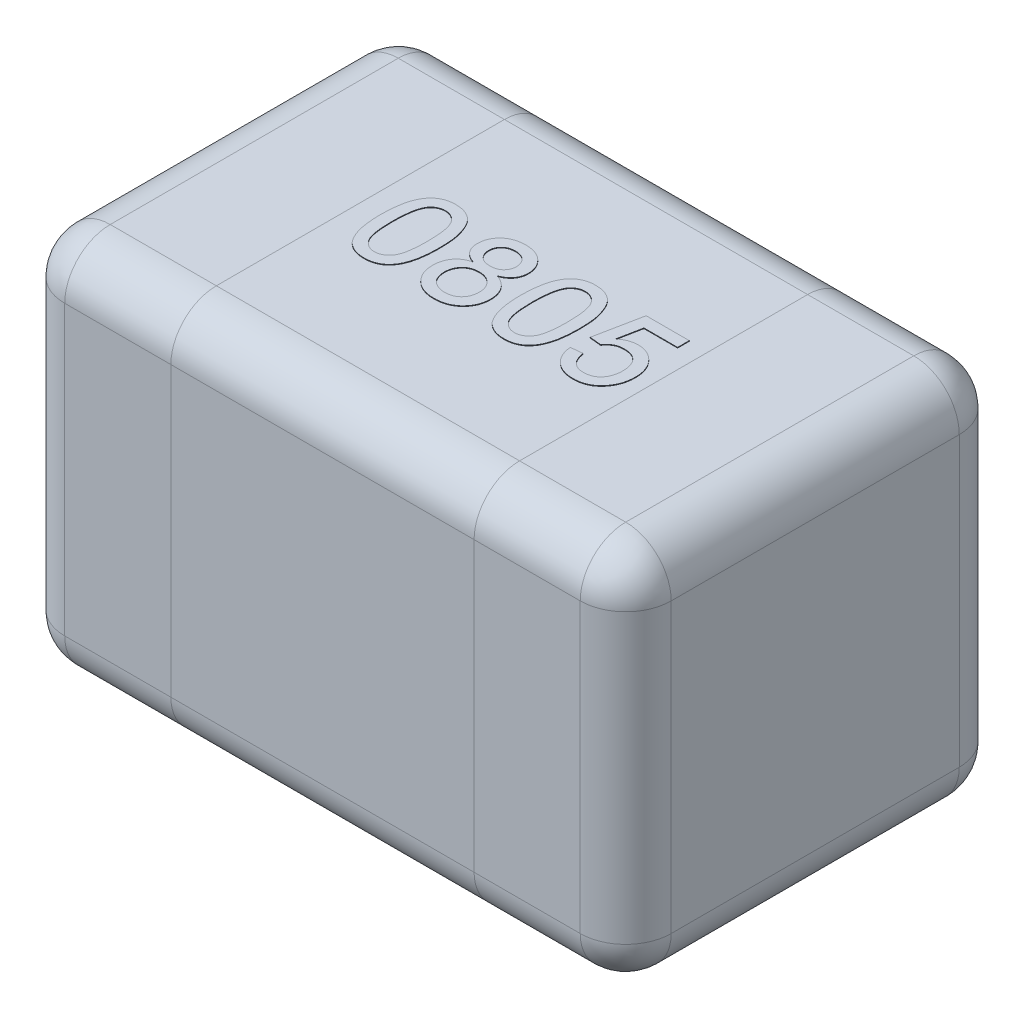
from build123d import *

# Parameters (mm, degrees)
SKETCH1_W      = 2
SKETCH1_H      = 1.25
EXTRUDE1_DEPTH = 1.25
FILLET1_R      = 0.15
EXTRUDE2_DEPTH = 0.002


with BuildPart() as part:
    # Sketch1 → Extrude1 (new body)
    with BuildSketch(Plane(origin=(0, 0, 0), x_dir=(1, 0, 0), z_dir=(0, 1, 0))):
        Rectangle(SKETCH1_W, SKETCH1_H)
    extrude(amount=EXTRUDE1_DEPTH)

    # Fillet1
    fillet1_edges = [part.edges().sort_by_distance(p)[0] for p in [
        (1, 1.25, 0),
        (0, 1.25, -0.625),
        (-1, 1.25, 0),
        (0, 0, -0.625),
        (1, 0, 0),
        (0, 0, 0.625),
        (-1, 0, 0),
        (0, 1.25, 0.625),
        (-1, 0.625, -0.625),
        (1, 0.625, -0.625),
        (1, 0.625, 0.625),
        (-1, 0.625, 0.625),
    ]]
    fillet(fillet1_edges, radius=FILLET1_R)

    # Sketch3 → Extrude2 (add)
    with BuildSketch(Plane(origin=(0, 1.25, 0), x_dir=(1, 0, 0), z_dir=(0, 1, 0))):
        with BuildLine():
            add(Edge.make_bspline(
                [(-0.430769231, -0.002043269), (-0.430730481, 0.002244006), (-0.430654586, 0.010640973), (-0.430183834, 0.022927244), (-0.42936194, 0.034595007), (-0.428135078, 0.045634129), (-0.426682243, 0.056069528), (-0.424793549, 0.06588631), (-0.422668494, 0.075106502), (-0.420118809, 0.083720493), (-0.41731754, 0.091802347), (-0.414139411, 0.0993391), (-0.410563584, 0.106322761), (-0.40676579, 0.112825754), (-0.402546105, 0.118746931), (-0.39815922, 0.124252464), (-0.393286323, 0.129140445), (-0.388130039, 0.13353664), (-0.382614442, 0.137416027), (-0.376768712, 0.140763469), (-0.370615345, 0.143719019), (-0.364037062, 0.145943957), (-0.357170429, 0.147757753), (-0.349962588, 0.149092003), (-0.342405598, 0.149878588), (-0.337241458, 0.149959072), (-0.334615385, 0.15)],
                knots=[0, 0, 0, 0, 1.2862e-05, 2.5191e-05, 3.688e-05, 4.7943e-05, 5.8507e-05, 6.8478e-05, 7.7924e-05, 8.6881e-05, 9.5415e-05, 0.000103574, 0.000111395, 0.00011894, 0.000126142, 0.000133191, 0.000140033, 0.000146812, 0.000153498, 0.000160229, 0.000167003, 0.000173941, 0.000181025, 0.000188297, 0.00019591, 0.000203786, 0.000203786, 0.000203786, 0.000203786], degree=3))
            add(Edge.make_bspline(
                [(-0.334615385, 0.15), (-0.330762593, 0.149886731), (-0.32319363, 0.149664209), (-0.312142905, 0.147849358), (-0.301728309, 0.144744777), (-0.291956608, 0.140556563), (-0.282994848, 0.135236725), (-0.274991618, 0.128769652), (-0.268033247, 0.121223246), (-0.262195674, 0.112508085), (-0.257093053, 0.102864591), (-0.252559996, 0.092249481), (-0.248462244, 0.080674651), (-0.24555439, 0.070313561), (-0.243480221, 0.061369501), (-0.242107285, 0.053992694), (-0.240967473, 0.046033077), (-0.240094223, 0.037509907), (-0.239377743, 0.028432744), (-0.238824437, 0.018795935), (-0.238543578, 0.008575397), (-0.238489398, 0.001562641), (-0.238461538, -0.002043269)],
                knots=[0, 0, 0, 0, 1.1554e-05, 2.2698e-05, 3.348e-05, 4.4085e-05, 5.4516e-05, 6.4643e-05, 7.485e-05, 8.5185e-05, 9.602e-05, 0.000107541, 0.000119781, 0.000132832, 0.000139801, 0.000147321, 0.000155335, 0.000163916, 0.000173019, 0.00018265, 0.000192871, 0.000203689, 0.000203689, 0.000203689, 0.000203689], degree=3))
            add(Edge.make_bspline(
                [(-0.238461538, -0.002043269), (-0.238501014, -0.006310407), (-0.238578138, -0.0146471), (-0.239036276, -0.026834856), (-0.239907695, -0.038414591), (-0.240979992, -0.049412832), (-0.242602154, -0.059800218), (-0.24435012, -0.069620882), (-0.246511923, -0.07883023), (-0.249034239, -0.087432298), (-0.251874941, -0.095472571), (-0.254990209, -0.103011813), (-0.258440668, -0.110044871), (-0.262329015, -0.11650315), (-0.266477343, -0.122472371), (-0.270916032, -0.127974928), (-0.275739189, -0.132931621), (-0.280941938, -0.137314631), (-0.28641881, -0.141262812), (-0.292278751, -0.144643304), (-0.298496114, -0.147443983), (-0.305029358, -0.149838424), (-0.311944772, -0.15159293), (-0.319187822, -0.152935977), (-0.326785196, -0.153726861), (-0.331969311, -0.153805841), (-0.334615385, -0.153846154)],
                knots=[0, 0, 0, 0, 1.2802e-05, 2.5011e-05, 3.658e-05, 4.7637e-05, 5.815e-05, 6.811e-05, 7.7556e-05, 8.6513e-05, 9.499e-05, 0.000103126, 0.000110974, 0.000118467, 0.000125719, 0.000132767, 0.000139652, 0.000146431, 0.000153152, 0.000159883, 0.000166686, 0.000173587, 0.000180729, 0.000188061, 0.000195673, 0.00020361, 0.00020361, 0.00020361, 0.00020361], degree=3))
            add(Edge.make_bspline(
                [(-0.334615385, -0.153846154), (-0.338084694, -0.153747192), (-0.344848894, -0.153554242), (-0.354727508, -0.152243272), (-0.363999114, -0.149935902), (-0.372741914, -0.146841394), (-0.380857634, -0.142702311), (-0.388385026, -0.137666308), (-0.395475345, -0.131850554), (-0.399556964, -0.127262057), (-0.401622596, -0.124939904)],
                knots=[0, 0, 0, 0, 1.0408e-05, 2.0292e-05, 2.9825e-05, 3.9025e-05, 4.8056e-05, 5.7073e-05, 6.616e-05, 7.5471e-05, 7.5471e-05, 7.5471e-05, 7.5471e-05], degree=3))
            add(Edge.make_bspline(
                [(-0.401622596, -0.124939904), (-0.404000186, -0.121510195), (-0.408902879, -0.11443799), (-0.414641055, -0.102379223), (-0.41975961, -0.089104214), (-0.423776737, -0.074352508), (-0.426923149, -0.058241513), (-0.429195644, -0.040739616), (-0.430481652, -0.021854376), (-0.430671207, -0.008796046), (-0.430769231, -0.002043269)],
                knots=[0, 0, 0, 0, 1.2501e-05, 2.5778e-05, 3.993e-05, 5.5152e-05, 7.157e-05, 8.9147e-05, 0.000108063, 0.000128321, 0.000128321, 0.000128321, 0.000128321], degree=3))
        make_face()
        with BuildLine():
            add(Edge.make_bspline(
                [(-0.392307692, -0.001923077), (-0.392269503, -0.007693168), (-0.3921964, -0.018738399), (-0.391432655, -0.034518417), (-0.390117899, -0.048754147), (-0.388379705, -0.061425879), (-0.386084585, -0.072550754), (-0.383202791, -0.082100422), (-0.379954324, -0.090189501), (-0.375934407, -0.096717734), (-0.371533042, -0.102039196), (-0.366988934, -0.106615825), (-0.362195175, -0.110505855), (-0.357183043, -0.113749347), (-0.351874773, -0.116205105), (-0.346328409, -0.117985045), (-0.340542745, -0.119009373), (-0.336602445, -0.119156549), (-0.334615385, -0.119230769)],
                knots=[0, 0, 0, 0, 1.7309e-05, 3.3134e-05, 4.7378e-05, 6.0186e-05, 7.1489e-05, 8.1413e-05, 9.0085e-05, 9.7558e-05, 0.000104306, 0.000110765, 0.000116876, 0.000122794, 0.000128628, 0.000134368, 0.000140227, 0.000146187, 0.000146187, 0.000146187, 0.000146187], degree=3))
            add(Edge.make_bspline(
                [(-0.334615385, -0.119230769), (-0.332628822, -0.119154928), (-0.328689509, -0.119004535), (-0.322890476, -0.118002795), (-0.317365692, -0.116131225), (-0.312065336, -0.11368414), (-0.307016775, -0.110514577), (-0.30224656, -0.106609854), (-0.297678514, -0.102035942), (-0.29329692, -0.096652628), (-0.289307629, -0.090094213), (-0.285998225, -0.082011723), (-0.283161342, -0.072445331), (-0.280853628, -0.061326124), (-0.279108264, -0.048674427), (-0.277801457, -0.03447818), (-0.2770326, -0.018718466), (-0.276960704, -0.007693194), (-0.276923077, -0.001923077)],
                knots=[0, 0, 0, 0, 5.96e-06, 1.1819e-05, 1.7578e-05, 2.3412e-05, 2.9298e-05, 3.5408e-05, 4.1867e-05, 4.8662e-05, 5.6186e-05, 6.4803e-05, 7.4784e-05, 8.6088e-05, 9.8836e-05, 0.00011308, 0.000128845, 0.000146154, 0.000146154, 0.000146154, 0.000146154], degree=3))
            add(Edge.make_bspline(
                [(-0.276923077, -0.001923077), (-0.276959499, 0.003726983), (-0.277029283, 0.014552283), (-0.27781797, 0.030028299), (-0.279053912, 0.044025088), (-0.280744486, 0.056555555), (-0.282991257, 0.067606095), (-0.285716284, 0.077200235), (-0.288963562, 0.085317512), (-0.292824563, 0.092039466), (-0.29712263, 0.097553292), (-0.301612368, 0.102325988), (-0.306406022, 0.10638501), (-0.31158852, 0.109641218), (-0.316992821, 0.112268205), (-0.322743102, 0.114076165), (-0.328782842, 0.115186918), (-0.332927837, 0.115317963), (-0.335036058, 0.115384615)],
                knots=[0, 0, 0, 0, 1.6949e-05, 3.2473e-05, 4.6473e-05, 5.9094e-05, 7.0385e-05, 8.0274e-05, 8.8979e-05, 9.6545e-05, 0.000103444, 0.000109906, 0.000116177, 0.000122229, 0.000128223, 0.000134153, 0.000140259, 0.000146579, 0.000146579, 0.000146579, 0.000146579], degree=3))
            add(Edge.make_bspline(
                [(-0.335036058, 0.115384615), (-0.337022993, 0.115332466), (-0.340940974, 0.115229635), (-0.346677413, 0.114248109), (-0.352113768, 0.112606778), (-0.357312323, 0.110383437), (-0.362143298, 0.107391258), (-0.366798279, 0.103897677), (-0.371059245, 0.099641138), (-0.373626865, 0.096459016), (-0.374939904, 0.094831731)],
                knots=[0, 0, 0, 0, 5.957e-06, 1.1747e-05, 1.7393e-05, 2.2965e-05, 2.8654e-05, 3.4399e-05, 4.0391e-05, 4.6662e-05, 4.6662e-05, 4.6662e-05, 4.6662e-05], degree=3))
            add(Edge.make_bspline(
                [(-0.374939904, 0.094831731), (-0.376369403, 0.092441753), (-0.379388204, 0.087394622), (-0.382766067, 0.078622501), (-0.385749937, 0.068597636), (-0.388206652, 0.057165788), (-0.389983913, 0.044346567), (-0.391386991, 0.03015486), (-0.392115838, 0.014570853), (-0.392241977, 0.003726591), (-0.392307692, -0.001923077)],
                knots=[0, 0, 0, 0, 8.341e-06, 1.7615e-05, 2.8091e-05, 3.9714e-05, 5.2649e-05, 6.6899e-05, 8.2483e-05, 9.9433e-05, 9.9433e-05, 9.9433e-05, 9.9433e-05], degree=3))
        make_face(mode=Mode.SUBTRACT)
        with BuildLine():
            add(Edge.make_bspline(
                [(-0.143028846, 0.014543269), (-0.146678167, 0.015970904), (-0.153675125, 0.018708154), (-0.163112218, 0.024186161), (-0.171099208, 0.030487887), (-0.177538027, 0.037765293), (-0.182445577, 0.045867936), (-0.185979208, 0.054692508), (-0.188048917, 0.06428817), (-0.188321315, 0.070923324), (-0.188461538, 0.074338942)],
                knots=[0, 0, 0, 0, 1.1742e-05, 2.2513e-05, 3.2603e-05, 4.214e-05, 5.1498e-05, 6.0884e-05, 7.0537e-05, 8.0779e-05, 8.0779e-05, 8.0779e-05, 8.0779e-05], degree=3))
            add(Edge.make_bspline(
                [(-0.188461538, 0.074338942), (-0.188395542, 0.07696711), (-0.188265988, 0.082126286), (-0.187146613, 0.089696504), (-0.185353774, 0.096950666), (-0.182809315, 0.103868299), (-0.179621525, 0.11050634), (-0.175599072, 0.11674318), (-0.170975512, 0.122755082), (-0.165559231, 0.128299027), (-0.159590583, 0.133376745), (-0.153125606, 0.137895415), (-0.146114829, 0.141590589), (-0.138675143, 0.144680065), (-0.130769761, 0.147098798), (-0.122370837, 0.148746091), (-0.113507979, 0.149793891), (-0.107434938, 0.149930227), (-0.104326923, 0.15)],
                knots=[0, 0, 0, 0, 7.881e-06, 1.547e-05, 2.2904e-05, 3.0261e-05, 3.7545e-05, 4.4948e-05, 5.2485e-05, 6.0262e-05, 6.8149e-05, 7.5968e-05, 8.3872e-05, 9.1874e-05, 0.000100106, 0.000108627, 0.00011752, 0.000126842, 0.000126842, 0.000126842, 0.000126842], degree=3))
            add(Edge.make_bspline(
                [(-0.104326923, 0.15), (-0.101199104, 0.149929518), (-0.095106464, 0.149792228), (-0.086196519, 0.148758507), (-0.077744593, 0.147025925), (-0.06975566, 0.144567827), (-0.062217127, 0.141425001), (-0.05517853, 0.137562056), (-0.048567409, 0.133042703), (-0.042552743, 0.127813048), (-0.037080114, 0.122135343), (-0.032338597, 0.1160526), (-0.02827195, 0.109706754), (-0.024911477, 0.103059254), (-0.022425386, 0.096034402), (-0.020530427, 0.088764549), (-0.019431263, 0.081163316), (-0.019298434, 0.076005089), (-0.019230769, 0.073377404)],
                knots=[0, 0, 0, 0, 9.382e-06, 1.8275e-05, 2.6867e-05, 3.5231e-05, 4.3312e-05, 5.1326e-05, 5.9277e-05, 6.7288e-05, 7.5194e-05, 8.29e-05, 9.0385e-05, 9.7776e-05, 0.00010519, 0.000112697, 0.000120286, 0.000128167, 0.000128167, 0.000128167, 0.000128167], degree=3))
            add(Edge.make_bspline(
                [(-0.019230769, 0.073377404), (-0.019340689, 0.070079507), (-0.019556221, 0.063612951), (-0.021752586, 0.054291357), (-0.025175809, 0.045589182), (-0.030123399, 0.037672273), (-0.036389338, 0.030458869), (-0.044164868, 0.024188177), (-0.053331905, 0.018718731), (-0.060152201, 0.015972556), (-0.063701923, 0.014543269)],
                knots=[0, 0, 0, 0, 9.878e-06, 1.9369e-05, 2.8564e-05, 3.782e-05, 4.7233e-05, 5.7098e-05, 6.7662e-05, 7.9128e-05, 7.9128e-05, 7.9128e-05, 7.9128e-05], degree=3))
            add(Edge.make_bspline(
                [(-0.063701923, 0.014543269), (-0.061462279, 0.013783016), (-0.057073548, 0.01229325), (-0.050869192, 0.009396685), (-0.045027977, 0.006273501), (-0.039516964, 0.002892652), (-0.034539578, -0.000997287), (-0.02992976, -0.00516632), (-0.02570689, -0.009673198), (-0.021928648, -0.014556251), (-0.018555448, -0.019712993), (-0.015667721, -0.025155995), (-0.01321523, -0.030807785), (-0.011119246, -0.036694571), (-0.009588296, -0.042857817), (-0.008517111, -0.049269202), (-0.007837474, -0.055894934), (-0.0077412, -0.060394987), (-0.007692308, -0.062680288)],
                knots=[0, 0, 0, 0, 7.091e-06, 1.3894e-05, 2.0509e-05, 2.6962e-05, 3.326e-05, 3.9429e-05, 4.5594e-05, 5.1761e-05, 5.7929e-05, 6.4058e-05, 7.0221e-05, 7.6399e-05, 8.2783e-05, 8.9244e-05, 9.5888e-05, 0.000102743, 0.000102743, 0.000102743, 0.000102743], degree=3))
            add(Edge.make_bspline(
                [(-0.007692308, -0.062680288), (-0.007768742, -0.065830053), (-0.007919323, -0.07203533), (-0.009242375, -0.081143948), (-0.011244211, -0.089894018), (-0.014163119, -0.098248578), (-0.017891291, -0.106213532), (-0.022503083, -0.113777315), (-0.027953185, -0.120932146), (-0.034080828, -0.127700265), (-0.040931529, -0.133818351), (-0.048342718, -0.139209736), (-0.056342204, -0.143725707), (-0.064832924, -0.147464915), (-0.073855537, -0.150362788), (-0.083398443, -0.152391913), (-0.093458467, -0.153600168), (-0.100337199, -0.15376306), (-0.103846154, -0.153846154)],
                knots=[0, 0, 0, 0, 9.444e-06, 1.8606e-05, 2.7557e-05, 3.6337e-05, 4.5101e-05, 5.3893e-05, 6.2859e-05, 7.2048e-05, 8.1241e-05, 9.0365e-05, 9.9489e-05, 0.000108745, 0.000118153, 0.000127865, 0.000137973, 0.000148498, 0.000148498, 0.000148498, 0.000148498], degree=3))
            add(Edge.make_bspline(
                [(-0.103846154, -0.153846154), (-0.107354757, -0.153761269), (-0.114232802, -0.153594866), (-0.124302017, -0.152411313), (-0.13383127, -0.150290202), (-0.142842151, -0.147389384), (-0.15138354, -0.143751415), (-0.159329302, -0.139133687), (-0.166788901, -0.133749133), (-0.173644365, -0.127593205), (-0.179822907, -0.120825808), (-0.185201165, -0.113565311), (-0.18978558, -0.105923451), (-0.193558454, -0.097857148), (-0.196434244, -0.089366329), (-0.198452508, -0.080482873), (-0.199777955, -0.071213566), (-0.199924942, -0.064888503), (-0.2, -0.061658654)],
                knots=[0, 0, 0, 0, 1.0525e-05, 2.0633e-05, 3.0358e-05, 3.9766e-05, 4.8998e-05, 5.8152e-05, 6.7276e-05, 7.6554e-05, 8.5742e-05, 9.4721e-05, 0.000103615, 0.000112434, 0.000121385, 0.000130452, 0.000139733, 0.000149418, 0.000149418, 0.000149418, 0.000149418], degree=3))
            add(Edge.make_bspline(
                [(-0.2, -0.061658654), (-0.199947829, -0.05925379), (-0.199845461, -0.054535032), (-0.199220126, -0.047613898), (-0.197973847, -0.04101733), (-0.19636856, -0.034706454), (-0.194330348, -0.028665483), (-0.191815826, -0.022941855), (-0.188765062, -0.017549405), (-0.185299194, -0.012453043), (-0.181374488, -0.007688549), (-0.177054552, -0.003297645), (-0.172323696, 0.000669723), (-0.16728823, 0.004329433), (-0.161737085, 0.007422605), (-0.155876706, 0.010261167), (-0.149606339, 0.012681934), (-0.145243302, 0.01391661), (-0.143028846, 0.014543269)],
                knots=[0, 0, 0, 0, 7.216e-06, 1.4158e-05, 2.0818e-05, 2.7333e-05, 3.3681e-05, 3.9923e-05, 4.6058e-05, 5.2242e-05, 5.839e-05, 6.4552e-05, 7.0692e-05, 7.6896e-05, 8.3194e-05, 8.9726e-05, 9.6422e-05, 0.000103324, 0.000103324, 0.000103324, 0.000103324], degree=3))
        make_face()
        with BuildLine():
            add(Edge.make_bspline(
                [(-0.15, 0.074158654), (-0.149885847, 0.071096846), (-0.149665252, 0.065180074), (-0.147266257, 0.056775734), (-0.143514926, 0.049226279), (-0.139117148, 0.043751589), (-0.134900784, 0.0400214), (-0.131381647, 0.037530885), (-0.127535911, 0.035416488), (-0.123335716, 0.033773046), (-0.11888279, 0.032317058), (-0.114023557, 0.031503267), (-0.108872232, 0.030841703), (-0.105311001, 0.03079379), (-0.103485577, 0.030769231)],
                knots=[0, 0, 0, 0, 9.163e-06, 1.7707e-05, 2.5985e-05, 3.4319e-05, 3.8576e-05, 4.2845e-05, 4.7228e-05, 5.1704e-05, 5.6361e-05, 6.1252e-05, 6.6455e-05, 7.1927e-05, 7.1927e-05, 7.1927e-05, 7.1927e-05], degree=3))
            add(Edge.make_bspline(
                [(-0.103485577, 0.030769231), (-0.101700447, 0.030794697), (-0.098219542, 0.030844356), (-0.093184237, 0.031492433), (-0.088425891, 0.032358), (-0.08401482, 0.033669634), (-0.079900096, 0.035375141), (-0.076148645, 0.037477611), (-0.072648204, 0.039893951), (-0.068555701, 0.043652639), (-0.064163992, 0.048935583), (-0.060400089, 0.056147793), (-0.058054585, 0.064038379), (-0.057815187, 0.069534632), (-0.057692308, 0.072355769)],
                knots=[0, 0, 0, 0, 5.352e-06, 1.0435e-05, 1.5209e-05, 1.9848e-05, 2.4212e-05, 2.8543e-05, 3.2728e-05, 3.694e-05, 4.5181e-05, 5.3192e-05, 6.1199e-05, 6.9644e-05, 6.9644e-05, 6.9644e-05, 6.9644e-05], degree=3))
            add(Edge.make_bspline(
                [(-0.057692308, 0.072355769), (-0.05784036, 0.075275526), (-0.05813006, 0.080988733), (-0.060469834, 0.089190299), (-0.06440905, 0.096618469), (-0.068909058, 0.102043156), (-0.073073957, 0.105973023), (-0.076637241, 0.108474646), (-0.080467784, 0.110603749), (-0.084580166, 0.112342448), (-0.088980333, 0.113744726), (-0.093680205, 0.114664689), (-0.098660033, 0.115309891), (-0.102081073, 0.115359183), (-0.103846154, 0.115384615)],
                knots=[0, 0, 0, 0, 8.749e-06, 1.7119e-05, 2.5345e-05, 3.3802e-05, 3.814e-05, 4.2492e-05, 4.6823e-05, 5.1266e-05, 5.5866e-05, 6.0651e-05, 6.5615e-05, 7.0907e-05, 7.0907e-05, 7.0907e-05, 7.0907e-05], degree=3))
            add(Edge.make_bspline(
                [(-0.103846154, 0.115384615), (-0.105611431, 0.115360006), (-0.109052754, 0.11531203), (-0.114065054, 0.114647467), (-0.118809467, 0.113812789), (-0.123242222, 0.112473285), (-0.127344894, 0.110722865), (-0.131160335, 0.108592567), (-0.134716868, 0.106154844), (-0.138911028, 0.102400216), (-0.14330372, 0.097117152), (-0.147173559, 0.09002013), (-0.149565244, 0.08228198), (-0.149853286, 0.076899968), (-0.15, 0.074158654)],
                knots=[0, 0, 0, 0, 5.292e-06, 1.0316e-05, 1.5148e-05, 1.973e-05, 2.4173e-05, 2.8504e-05, 3.2821e-05, 3.7078e-05, 4.5358e-05, 5.3291e-05, 6.12e-05, 6.941e-05, 6.941e-05, 6.941e-05, 6.941e-05], degree=3))
        make_face(mode=Mode.SUBTRACT)
        with BuildLine():
            add(Edge.make_bspline(
                [(-0.161538462, -0.0609375), (-0.161471953, -0.063405403), (-0.16133876, -0.06834771), (-0.160170375, -0.075688083), (-0.158187867, -0.082891764), (-0.155646938, -0.089965559), (-0.1520628, -0.096623957), (-0.147309829, -0.102567066), (-0.141345741, -0.107563675), (-0.134534427, -0.111784999), (-0.127101532, -0.115107544), (-0.119356237, -0.117426794), (-0.111498446, -0.118959238), (-0.106196901, -0.119140248), (-0.103545673, -0.119230769)],
                knots=[0, 0, 0, 0, 7.401e-06, 1.4821e-05, 2.2226e-05, 2.9795e-05, 3.7325e-05, 4.4805e-05, 5.2477e-05, 6.0548e-05, 6.8779e-05, 7.6821e-05, 8.4765e-05, 9.2713e-05, 9.2713e-05, 9.2713e-05, 9.2713e-05], degree=3))
            add(Edge.make_bspline(
                [(-0.103545673, -0.119230769), (-0.10135945, -0.119193736), (-0.097112242, -0.119121792), (-0.090921142, -0.11829967), (-0.085087726, -0.117052243), (-0.079585269, -0.115341816), (-0.074494761, -0.113001839), (-0.069733304, -0.110266914), (-0.065349603, -0.106961547), (-0.061344897, -0.10318929), (-0.057759976, -0.099016466), (-0.054689038, -0.094514901), (-0.052010223, -0.08981119), (-0.049823092, -0.08480382), (-0.048241444, -0.079482465), (-0.04702098, -0.073943134), (-0.046284709, -0.068128692), (-0.046198099, -0.064164781), (-0.046153846, -0.062139423)],
                knots=[0, 0, 0, 0, 6.555e-06, 1.2734e-05, 1.8699e-05, 2.4438e-05, 2.9979e-05, 3.5473e-05, 4.0881e-05, 4.6408e-05, 5.1949e-05, 5.735e-05, 6.2732e-05, 6.8169e-05, 7.37e-05, 7.9358e-05, 8.5173e-05, 9.1247e-05, 9.1247e-05, 9.1247e-05, 9.1247e-05], degree=3))
            add(Edge.make_bspline(
                [(-0.046153846, -0.062139423), (-0.046199509, -0.06007431), (-0.046288909, -0.056031148), (-0.047006468, -0.050089091), (-0.048295369, -0.044452304), (-0.0499529, -0.039035631), (-0.052199329, -0.033933308), (-0.054895853, -0.029072172), (-0.058197999, -0.024580352), (-0.061819065, -0.020305352), (-0.0659169, -0.016435488), (-0.070442192, -0.013098358), (-0.075251524, -0.010151107), (-0.080490384, -0.007890317), (-0.086043352, -0.006079372), (-0.09193681, -0.004763512), (-0.098194786, -0.003959162), (-0.102481472, -0.003884551), (-0.1046875, -0.003846154)],
                knots=[0, 0, 0, 0, 6.195e-06, 1.2128e-05, 1.7916e-05, 2.3523e-05, 2.9094e-05, 3.4611e-05, 4.0164e-05, 4.579e-05, 5.1402e-05, 5.7027e-05, 6.2633e-05, 6.8284e-05, 7.4099e-05, 8.0135e-05, 8.6374e-05, 9.2989e-05, 9.2989e-05, 9.2989e-05, 9.2989e-05], degree=3))
            add(Edge.make_bspline(
                [(-0.1046875, -0.003846154), (-0.106833622, -0.003884933), (-0.11104069, -0.003960952), (-0.117152397, -0.004769858), (-0.122938306, -0.00601207), (-0.128347512, -0.007830212), (-0.133447646, -0.010102166), (-0.13814543, -0.012958985), (-0.142524672, -0.016274938), (-0.1464516, -0.020129101), (-0.149994708, -0.02431577), (-0.153058103, -0.028803867), (-0.155764303, -0.033489281), (-0.157817981, -0.038525757), (-0.159556235, -0.043750476), (-0.160642919, -0.049264843), (-0.161415415, -0.055006205), (-0.161496847, -0.058931505), (-0.161538462, -0.0609375)],
                knots=[0, 0, 0, 0, 6.435e-06, 1.2614e-05, 1.8461e-05, 2.4162e-05, 2.9703e-05, 3.5176e-05, 4.0621e-05, 4.6146e-05, 5.1647e-05, 5.7048e-05, 6.243e-05, 6.7843e-05, 7.3336e-05, 7.8923e-05, 8.4677e-05, 9.0691e-05, 9.0691e-05, 9.0691e-05, 9.0691e-05], degree=3))
        make_face(mode=Mode.SUBTRACT)
        with BuildLine():
            add(Edge.make_bspline(
                [(0.030769231, -0.002043269), (0.030807981, 0.002244006), (0.030883876, 0.010640973), (0.031354627, 0.022927244), (0.032176522, 0.034595007), (0.033403384, 0.045634129), (0.034856218, 0.056069528), (0.036744912, 0.06588631), (0.038869967, 0.075106502), (0.041419652, 0.083720493), (0.044220921, 0.091802347), (0.047399051, 0.0993391), (0.050974877, 0.106322761), (0.054772671, 0.112825754), (0.058992356, 0.118746931), (0.063379241, 0.124252464), (0.068252138, 0.129140445), (0.073408422, 0.13353664), (0.07892402, 0.137416027), (0.084769749, 0.140763469), (0.090923117, 0.143719019), (0.097501399, 0.145943957), (0.104368033, 0.147757753), (0.111575873, 0.149092003), (0.119132863, 0.149878588), (0.124297003, 0.149959072), (0.126923077, 0.15)],
                knots=[0, 0, 0, 0, 1.2862e-05, 2.5191e-05, 3.688e-05, 4.7943e-05, 5.8507e-05, 6.8478e-05, 7.7924e-05, 8.6881e-05, 9.5415e-05, 0.000103574, 0.000111395, 0.00011894, 0.000126142, 0.000133191, 0.000140033, 0.000146812, 0.000153498, 0.000160229, 0.000167003, 0.000173941, 0.000181025, 0.000188297, 0.00019591, 0.000203786, 0.000203786, 0.000203786, 0.000203786], degree=3))
            add(Edge.make_bspline(
                [(0.126923077, 0.15), (0.130775868, 0.149886731), (0.138344831, 0.149664209), (0.149395556, 0.147849358), (0.159810153, 0.144744777), (0.169581854, 0.140556563), (0.178543614, 0.135236725), (0.186546843, 0.128769652), (0.193505214, 0.121223246), (0.199342787, 0.112508085), (0.204445409, 0.102864591), (0.208978466, 0.092249481), (0.213076217, 0.080674651), (0.215984071, 0.070313561), (0.218058241, 0.061369501), (0.219431176, 0.053992694), (0.220570988, 0.046033077), (0.221444238, 0.037509907), (0.222160719, 0.028432744), (0.222714024, 0.018795935), (0.222994883, 0.008575397), (0.223049064, 0.001562641), (0.223076923, -0.002043269)],
                knots=[0, 0, 0, 0, 1.1554e-05, 2.2698e-05, 3.348e-05, 4.4085e-05, 5.4516e-05, 6.4643e-05, 7.485e-05, 8.5185e-05, 9.602e-05, 0.000107541, 0.000119781, 0.000132832, 0.000139801, 0.000147321, 0.000155335, 0.000163916, 0.000173019, 0.00018265, 0.000192871, 0.000203689, 0.000203689, 0.000203689, 0.000203689], degree=3))
            add(Edge.make_bspline(
                [(0.223076923, -0.002043269), (0.223037447, -0.006310407), (0.222960323, -0.0146471), (0.222502186, -0.026834856), (0.221630766, -0.038414591), (0.220558469, -0.049412832), (0.218936308, -0.059800218), (0.217188341, -0.069620882), (0.215026538, -0.07883023), (0.212504222, -0.087432298), (0.209663521, -0.095472571), (0.206548253, -0.103011813), (0.203097794, -0.110044871), (0.199209446, -0.11650315), (0.195061119, -0.122472371), (0.190622429, -0.127974928), (0.185799273, -0.132931621), (0.180596523, -0.137314631), (0.175119652, -0.141262812), (0.16925971, -0.144643304), (0.163042348, -0.147443983), (0.156509104, -0.149838424), (0.149593689, -0.15159293), (0.142350639, -0.152935977), (0.134753266, -0.153726861), (0.129569151, -0.153805841), (0.126923077, -0.153846154)],
                knots=[0, 0, 0, 0, 1.2802e-05, 2.5011e-05, 3.658e-05, 4.7637e-05, 5.815e-05, 6.811e-05, 7.7556e-05, 8.6513e-05, 9.499e-05, 0.000103126, 0.000110974, 0.000118467, 0.000125719, 0.000132767, 0.000139652, 0.000146431, 0.000153152, 0.000159883, 0.000166686, 0.000173587, 0.000180729, 0.000188061, 0.000195673, 0.00020361, 0.00020361, 0.00020361, 0.00020361], degree=3))
            add(Edge.make_bspline(
                [(0.126923077, -0.153846154), (0.123453767, -0.153747192), (0.116689568, -0.153554242), (0.106810954, -0.152243272), (0.097539347, -0.149935902), (0.088796548, -0.146841394), (0.080680827, -0.142702311), (0.073153436, -0.137666308), (0.066063116, -0.131850554), (0.061981497, -0.127262057), (0.059915865, -0.124939904)],
                knots=[0, 0, 0, 0, 1.0408e-05, 2.0292e-05, 2.9825e-05, 3.9025e-05, 4.8056e-05, 5.7073e-05, 6.616e-05, 7.5471e-05, 7.5471e-05, 7.5471e-05, 7.5471e-05], degree=3))
            add(Edge.make_bspline(
                [(0.059915865, -0.124939904), (0.057538275, -0.121510195), (0.052635583, -0.11443799), (0.046897407, -0.102379223), (0.041778852, -0.089104214), (0.037761725, -0.074352508), (0.034615313, -0.058241513), (0.032342818, -0.040739616), (0.031056809, -0.021854376), (0.030867254, -0.008796046), (0.030769231, -0.002043269)],
                knots=[0, 0, 0, 0, 1.2501e-05, 2.5778e-05, 3.993e-05, 5.5152e-05, 7.157e-05, 8.9147e-05, 0.000108063, 0.000128321, 0.000128321, 0.000128321, 0.000128321], degree=3))
        make_face()
        with BuildLine():
            add(Edge.make_bspline(
                [(0.069230769, -0.001923077), (0.069268958, -0.007693168), (0.069342061, -0.018738399), (0.070105807, -0.034518417), (0.071420563, -0.048754147), (0.073158757, -0.061425879), (0.075453876, -0.072550754), (0.07833567, -0.082100422), (0.081584138, -0.090189501), (0.085604055, -0.096717734), (0.090005419, -0.102039196), (0.094549528, -0.106615825), (0.099343287, -0.110505855), (0.104355418, -0.113749347), (0.109663688, -0.116205105), (0.115210052, -0.117985045), (0.120995717, -0.119009373), (0.124936017, -0.119156549), (0.126923077, -0.119230769)],
                knots=[0, 0, 0, 0, 1.7309e-05, 3.3134e-05, 4.7378e-05, 6.0186e-05, 7.1489e-05, 8.1413e-05, 9.0085e-05, 9.7558e-05, 0.000104306, 0.000110765, 0.000116876, 0.000122794, 0.000128628, 0.000134368, 0.000140227, 0.000146187, 0.000146187, 0.000146187, 0.000146187], degree=3))
            add(Edge.make_bspline(
                [(0.126923077, -0.119230769), (0.128909639, -0.119154928), (0.132848953, -0.119004535), (0.138647986, -0.118002795), (0.14417277, -0.116131225), (0.149473125, -0.11368414), (0.154521686, -0.110514577), (0.159291902, -0.106609854), (0.163859948, -0.102035942), (0.168241542, -0.096652628), (0.172230832, -0.090094213), (0.175540237, -0.082011723), (0.17837712, -0.072445331), (0.180684833, -0.061326124), (0.182430197, -0.048674427), (0.183737005, -0.03447818), (0.184505861, -0.018718466), (0.184577757, -0.007693194), (0.184615385, -0.001923077)],
                knots=[0, 0, 0, 0, 5.96e-06, 1.1819e-05, 1.7578e-05, 2.3412e-05, 2.9298e-05, 3.5408e-05, 4.1867e-05, 4.8662e-05, 5.6186e-05, 6.4803e-05, 7.4784e-05, 8.6088e-05, 9.8836e-05, 0.00011308, 0.000128845, 0.000146154, 0.000146154, 0.000146154, 0.000146154], degree=3))
            add(Edge.make_bspline(
                [(0.184615385, -0.001923077), (0.184578962, 0.003726983), (0.184509178, 0.014552283), (0.183720492, 0.030028299), (0.182484549, 0.044025088), (0.180793976, 0.056555555), (0.178547205, 0.067606095), (0.175822177, 0.077200235), (0.1725749, 0.085317512), (0.168713899, 0.092039466), (0.164415832, 0.097553292), (0.159926094, 0.102325988), (0.15513244, 0.10638501), (0.149949942, 0.109641218), (0.144545641, 0.112268205), (0.13879536, 0.114076165), (0.13275562, 0.115186918), (0.128610625, 0.115317963), (0.126502404, 0.115384615)],
                knots=[0, 0, 0, 0, 1.6949e-05, 3.2473e-05, 4.6473e-05, 5.9094e-05, 7.0385e-05, 8.0274e-05, 8.8979e-05, 9.6545e-05, 0.000103444, 0.000109906, 0.000116177, 0.000122229, 0.000128223, 0.000134153, 0.000140259, 0.000146579, 0.000146579, 0.000146579, 0.000146579], degree=3))
            add(Edge.make_bspline(
                [(0.126502404, 0.115384615), (0.124515469, 0.115332466), (0.120597487, 0.115229635), (0.114861049, 0.114248109), (0.109424694, 0.112606778), (0.104226139, 0.110383437), (0.099395163, 0.107391258), (0.094740182, 0.103897677), (0.090479217, 0.099641138), (0.087911597, 0.096459016), (0.086598558, 0.094831731)],
                knots=[0, 0, 0, 0, 5.957e-06, 1.1747e-05, 1.7393e-05, 2.2965e-05, 2.8654e-05, 3.4399e-05, 4.0391e-05, 4.6662e-05, 4.6662e-05, 4.6662e-05, 4.6662e-05], degree=3))
            add(Edge.make_bspline(
                [(0.086598558, 0.094831731), (0.085169059, 0.092441753), (0.082150258, 0.087394622), (0.078772395, 0.078622501), (0.075788524, 0.068597636), (0.07333181, 0.057165788), (0.071554549, 0.044346567), (0.07015147, 0.03015486), (0.069422623, 0.014570853), (0.069296485, 0.003726591), (0.069230769, -0.001923077)],
                knots=[0, 0, 0, 0, 8.341e-06, 1.7615e-05, 2.8091e-05, 3.9714e-05, 5.2649e-05, 6.6899e-05, 8.2483e-05, 9.9433e-05, 9.9433e-05, 9.9433e-05, 9.9433e-05], degree=3))
        make_face(mode=Mode.SUBTRACT)
        with BuildLine():
            Line((0.261538462, -0.069230769), (0.3, -0.065384615))
            add(Edge.make_bspline(
                [(0.3, -0.065384615), (0.30038083, -0.067551712), (0.301121602, -0.071767052), (0.302533227, -0.077868882), (0.304366525, -0.083537652), (0.306426438, -0.088822457), (0.308874991, -0.093667418), (0.31152802, -0.098149034), (0.314656724, -0.102108221), (0.317946137, -0.105752048), (0.321556518, -0.108962904), (0.325522707, -0.111669767), (0.329734042, -0.114031341), (0.334241818, -0.115964892), (0.339052942, -0.11738015), (0.344106181, -0.118499376), (0.349466606, -0.119063349), (0.353123988, -0.119174249), (0.354987981, -0.119230769)],
                knots=[0, 0, 0, 0, 6.601e-06, 1.2839e-05, 1.8769e-05, 2.4461e-05, 2.9836e-05, 3.5041e-05, 4.0053e-05, 4.4945e-05, 4.9756e-05, 5.4507e-05, 5.9322e-05, 6.4223e-05, 6.9184e-05, 7.4347e-05, 7.9729e-05, 8.5323e-05, 8.5323e-05, 8.5323e-05, 8.5323e-05], degree=3))
            add(Edge.make_bspline(
                [(0.354987981, -0.119230769), (0.357274683, -0.119175516), (0.361746428, -0.119067466), (0.368251971, -0.118153619), (0.374396983, -0.116646792), (0.380152061, -0.1145381), (0.385584673, -0.111915691), (0.390514594, -0.10852015), (0.395210632, -0.104703226), (0.399370595, -0.10015272), (0.403157331, -0.095198734), (0.406425568, -0.089791248), (0.409176962, -0.08400616), (0.411493335, -0.077844578), (0.413203807, -0.071271305), (0.414461998, -0.064321309), (0.415269706, -0.056990161), (0.415345769, -0.051965295), (0.415384615, -0.049399038)],
                knots=[0, 0, 0, 0, 6.858e-06, 1.341e-05, 1.9663e-05, 2.5804e-05, 3.177e-05, 3.7704e-05, 4.3721e-05, 4.9886e-05, 5.6149e-05, 6.2405e-05, 6.8802e-05, 7.5343e-05, 8.2122e-05, 8.9147e-05, 9.652e-05, 0.000104216, 0.000104216, 0.000104216, 0.000104216], degree=3))
            add(Edge.make_bspline(
                [(0.415384615, -0.049399038), (0.415340463, -0.04695343), (0.415254489, -0.042191262), (0.414530446, -0.035256754), (0.4133089, -0.028736217), (0.411728333, -0.022557785), (0.409549721, -0.016818003), (0.406965765, -0.01143365), (0.403800311, -0.006518997), (0.400278533, -0.001921019), (0.396256219, 0.002200882), (0.391679027, 0.005681305), (0.386726518, 0.008727379), (0.381298942, 0.011197555), (0.375393105, 0.013032802), (0.369067694, 0.01444486), (0.362257073, 0.015187545), (0.357573654, 0.015317745), (0.355168269, 0.015384615)],
                knots=[0, 0, 0, 0, 7.336e-06, 1.4284e-05, 2.0885e-05, 2.7226e-05, 3.3387e-05, 3.9274e-05, 4.5109e-05, 5.0891e-05, 5.6628e-05, 6.2325e-05, 6.8097e-05, 7.4041e-05, 8.016e-05, 8.662e-05, 9.3456e-05, 0.000100674, 0.000100674, 0.000100674, 0.000100674], degree=3))
            add(Edge.make_bspline(
                [(0.355168269, 0.015384615), (0.35217729, 0.015297123), (0.346441268, 0.015129334), (0.338199195, 0.013717778), (0.330696137, 0.011437589), (0.324017044, 0.008039245), (0.318049605, 0.003979366), (0.312669849, -0.000614572), (0.307833414, -0.005739463), (0.305180433, -0.009597911), (0.303846154, -0.011538462)],
                knots=[0, 0, 0, 0, 8.967e-06, 1.7197e-05, 2.5009e-05, 3.24e-05, 3.9584e-05, 4.6617e-05, 5.3591e-05, 6.0647e-05, 6.0647e-05, 6.0647e-05, 6.0647e-05], degree=3))
            Line((0.303846154, -0.011538462), (0.265384615, -0.007692308))
            Line((0.265384615, -0.007692308), (0.296153846, 0.146153846))
            Line((0.296153846, 0.146153846), (0.438461538, 0.146153846))
            Line((0.438461538, 0.146153846), (0.438461538, 0.107692308))
            Line((0.438461538, 0.107692308), (0.327584135, 0.107692308))
            Line((0.327584135, 0.107692308), (0.312319712, 0.029987981))
            add(Edge.make_bspline(
                [(0.312319712, 0.029987981), (0.314441916, 0.031580513), (0.318609591, 0.034707994), (0.325110415, 0.038803019), (0.331704195, 0.042254851), (0.338352546, 0.045081612), (0.345108278, 0.047283653), (0.351930625, 0.04881353), (0.358842815, 0.049847511), (0.363477847, 0.049949025), (0.365805288, 0.05)],
                knots=[0, 0, 0, 0, 7.957e-06, 1.5627e-05, 2.3019e-05, 3.0263e-05, 3.7276e-05, 4.4303e-05, 5.1221e-05, 5.8199e-05, 5.8199e-05, 5.8199e-05, 5.8199e-05], degree=3))
            add(Edge.make_bspline(
                [(0.365805288, 0.05), (0.368834296, 0.049920638), (0.374799147, 0.049764354), (0.383588562, 0.048480285), (0.391992721, 0.046300494), (0.400077546, 0.043364633), (0.407736429, 0.039472647), (0.415046948, 0.034760279), (0.42197959, 0.029188686), (0.428495161, 0.022862992), (0.434405043, 0.015840807), (0.43969458, 0.008351149), (0.444014786, 0.000244097), (0.447648375, -0.008268674), (0.450388905, -0.017326903), (0.452469064, -0.026802035), (0.453581256, -0.036812532), (0.453756472, -0.043627351), (0.453846154, -0.047115385)],
                knots=[0, 0, 0, 0, 9.084e-06, 1.7889e-05, 2.6576e-05, 3.5094e-05, 4.3641e-05, 5.2292e-05, 6.1143e-05, 7.028e-05, 7.9491e-05, 8.8643e-05, 9.7732e-05, 0.000106996, 0.000116367, 0.00012608, 0.000136061, 0.000146526, 0.000146526, 0.000146526, 0.000146526], degree=3))
            add(Edge.make_bspline(
                [(0.453846154, -0.047115385), (0.453778054, -0.050443542), (0.453643537, -0.057017604), (0.452541146, -0.066705698), (0.450725217, -0.07604094), (0.44829419, -0.085050973), (0.445009547, -0.093684628), (0.441025582, -0.101969792), (0.436429854, -0.109992917), (0.432744319, -0.114938711), (0.430889423, -0.117427885)],
                knots=[0, 0, 0, 0, 9.982e-06, 1.9718e-05, 2.9206e-05, 3.8493e-05, 4.7679e-05, 5.6872e-05, 6.6056e-05, 7.5361e-05, 7.5361e-05, 7.5361e-05, 7.5361e-05], degree=3))
            add(Edge.make_bspline(
                [(0.430889423, -0.117427885), (0.428532829, -0.120333533), (0.423897156, -0.126049256), (0.415870539, -0.133467922), (0.407241812, -0.139772767), (0.397959625, -0.144894997), (0.388086291, -0.149011142), (0.377500519, -0.151750282), (0.36633022, -0.153589724), (0.358661594, -0.153759501), (0.354747596, -0.153846154)],
                knots=[0, 0, 0, 0, 1.1212e-05, 2.2054e-05, 3.2681e-05, 4.3199e-05, 5.379e-05, 6.4679e-05, 7.5933e-05, 8.7664e-05, 8.7664e-05, 8.7664e-05, 8.7664e-05], degree=3))
            add(Edge.make_bspline(
                [(0.354747596, -0.153846154), (0.351519169, -0.153780666), (0.345203717, -0.153652558), (0.335956773, -0.152538848), (0.327161835, -0.150762874), (0.318816148, -0.148215578), (0.31089457, -0.144996831), (0.303489178, -0.140907918), (0.29647146, -0.136230457), (0.289995781, -0.130820335), (0.284095595, -0.124785969), (0.278808909, -0.118255214), (0.274207265, -0.111223812), (0.270292885, -0.103733837), (0.26703043, -0.095792473), (0.264534523, -0.087345515), (0.262557557, -0.078475843), (0.261881722, -0.072344773), (0.261538462, -0.069230769)],
                knots=[0, 0, 0, 0, 9.682e-06, 1.894e-05, 2.7898e-05, 3.6567e-05, 4.5082e-05, 5.3499e-05, 6.19e-05, 7.0348e-05, 7.8763e-05, 8.7181e-05, 9.5515e-05, 0.000103929, 0.0001125, 0.000121226, 0.000130326, 0.000139718, 0.000139718, 0.000139718, 0.000139718], degree=3))
        make_face()
    extrude(amount=EXTRUDE2_DEPTH)


solid = part.part
